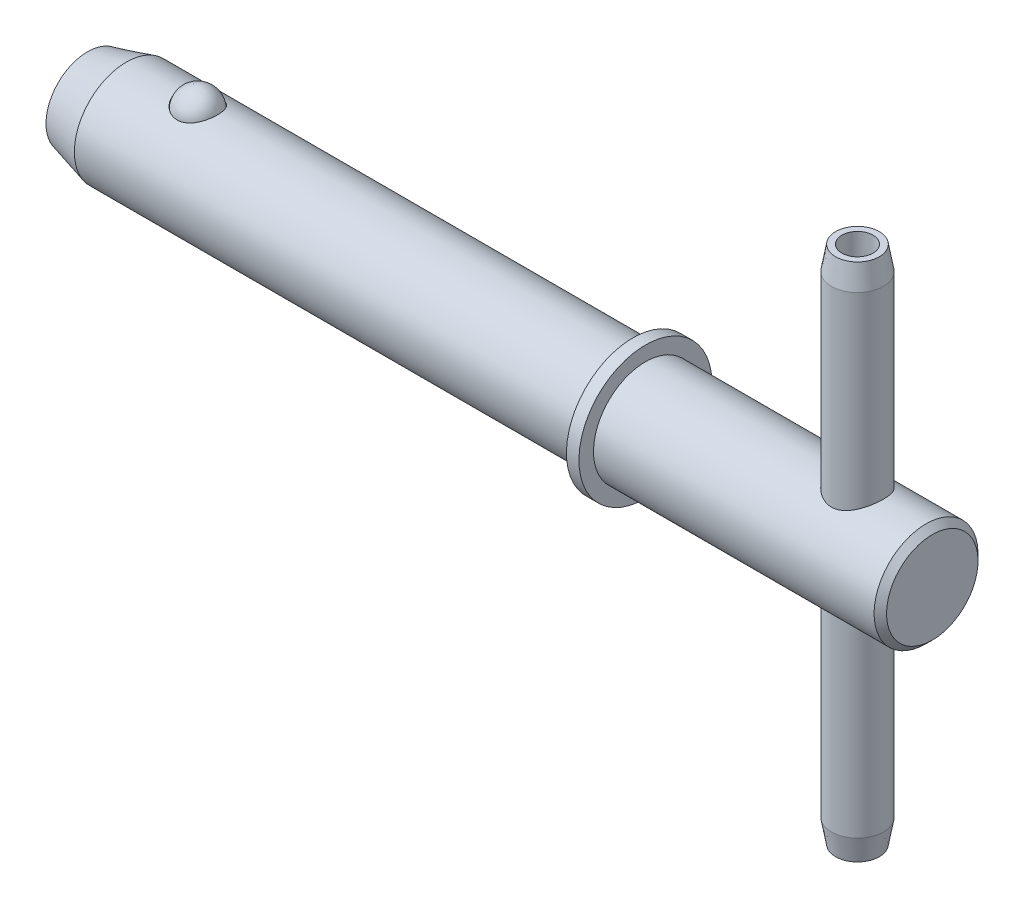
from build123d import *

# Parameters (mm, degrees)
SKETCH4_W      = 1.5875
SKETCH4_H      = 6.35
SKETCH5_W      = 0.762
SKETCH5_H      = 1.778
SKETCH5_2_W    = 0.762
SKETCH5_2_H    = 1.778
SKETCH6_R      = 1.5875
SKETCH6_R_2    = 0.9525
EXTRUDE1_DEPTH = 15.875
CHAMFER1_SIZE  = 0.254
CHAMFER1_SIZE2 = 1.440505582
CHAMFER2_SIZE  = 0.254
CHAMFER2_SIZE2 = 1.440505582


with BuildPart() as part:
    # Sketch1 → Revolve1 (revolve)
    with BuildSketch(Plane.XY, mode=Mode.PRIVATE) as revolve1_sk:
        Polygon((25.8064, 2.794), (25.4254, 3.175), (-23.436547737, 3.175), (-25.8064, 2.54), (-25.8064, 0), (25.8064, 0), align=None)
    revolve(revolve1_sk.sketch.rotate(Axis((25.8064, 0, 0), (1, 0, 0)), 180), axis=Axis((25.8064, 0, 0), (1, 0, 0)))  # turned: the seam where the file's is

    # Sketch2 → Cut-Revolve1 (revolve, cut)
    with BuildSketch(Plane.XY):
        with BuildLine():
            Line((-17.814582051, 2.8575), (-20.329182051, 2.8575))
            ThreePointArc((-20.329182051, 2.8575), (-19.071882051, 4.1148), (-17.814582051, 2.8575))
        make_face()
    revolve(axis=Axis((-17.814582051, 2.8575, 0), (1, 0, 0)), mode=Mode.SUBTRACT)

    # Sketch4 → Cut-Revolve2 (revolve, cut)
    with BuildSketch(Plane.XY, mode=Mode.PRIVATE) as cut_revolve2_sk:
        with Locations((22.02815, 0)):
            Rectangle(SKETCH4_W, SKETCH4_H)
    revolve(cut_revolve2_sk.sketch.rotate(Axis((21.2344, -3.175, 0), (0, 1, 0)), 180), axis=Axis((21.2344, -3.175, 0), (0, 1, 0)), mode=Mode.SUBTRACT)  # turned: the seam where the file's is

    # Sketch5 → Cut-Revolve3 (revolve, cut)
    with BuildSketch(Plane.XY, mode=Mode.PRIVATE) as cut_revolve3_sk:
        with Locations((7.8994, 3.175)):
            Rectangle(SKETCH5_W, SKETCH5_H)
    revolve(cut_revolve3_sk.sketch.rotate(Axis((7.5184, 0, 0), (1, 0, 0)), 180), axis=Axis((7.5184, 0, 0), (1, 0, 0)), mode=Mode.SUBTRACT)  # turned: the seam where the file's is


with BuildPart() as body_2:
    # Sketch3 → Revolve2 (revolve)
    with BuildSketch(Plane.XY):
        with BuildLine():
            Line((-17.839982051, 2.8575), (-20.303782051, 2.8575))
            ThreePointArc((-20.303782051, 2.8575), (-19.071882051, 4.0894), (-17.839982051, 2.8575))
        make_face()
    revolve(axis=Axis((-17.839982051, 2.8575, 0), (1, 0, 0)))


with BuildPart() as body_3:
    # Sketch5_2 → Revolve3 (revolve)
    with BuildSketch(Plane.XY, mode=Mode.PRIVATE) as revolve3_sk:
        with Locations((7.8994, 3.175)):
            Rectangle(SKETCH5_2_W, SKETCH5_2_H)
    revolve(revolve3_sk.sketch.rotate(Axis((7.5184, 0, 0), (1, 0, 0)), 180), axis=Axis((7.5184, 0, 0), (1, 0, 0)))  # turned: the seam where the file's is


with BuildPart() as body_4:
    # Sketch6 → Extrude1 (new body, symmetric)
    with BuildSketch(Plane(origin=(0, 0, 0), x_dir=(1, 0, 0), z_dir=(0, 1, 0))):
        with Locations(Location((21.2344, 0, 0), (0, 0, 270))):  # turned: the seam where the file's is
            Circle(SKETCH6_R)
        with Locations(Location((21.2344, 0, 0), (0, 0, 270))):  # turned: the seam where the file's is
            Circle(SKETCH6_R_2, mode=Mode.SUBTRACT)
    extrude(amount=EXTRUDE1_DEPTH, both=True)

    # Chamfer1
    chamfer1_edges = [body_4.edges().sort_by_distance(p)[0] for p in [
        (21.2344, 15.875, -1.5875),
    ]]
    chamfer1_side = [body_4.faces().sort_by_distance(p)[0] for p in [
        (21.2344, 15.875, -1.542598719),
    ]]
    chamfer(chamfer1_edges, length=CHAMFER1_SIZE, length2=CHAMFER1_SIZE2, reference=chamfer1_side[0])

    # Chamfer2
    chamfer2_edges = [body_4.edges().sort_by_distance(p)[0] for p in [
        (21.2344, -15.875, -1.5875),
    ]]
    chamfer2_side = [body_4.faces().sort_by_distance(p)[0] for p in [
        (21.2344, -15.875, -1.542598719),
    ]]
    chamfer(chamfer2_edges, length=CHAMFER2_SIZE, length2=CHAMFER2_SIZE2, reference=chamfer2_side[0])


solid = Compound([part.part, body_2.part, body_3.part, body_4.part])
